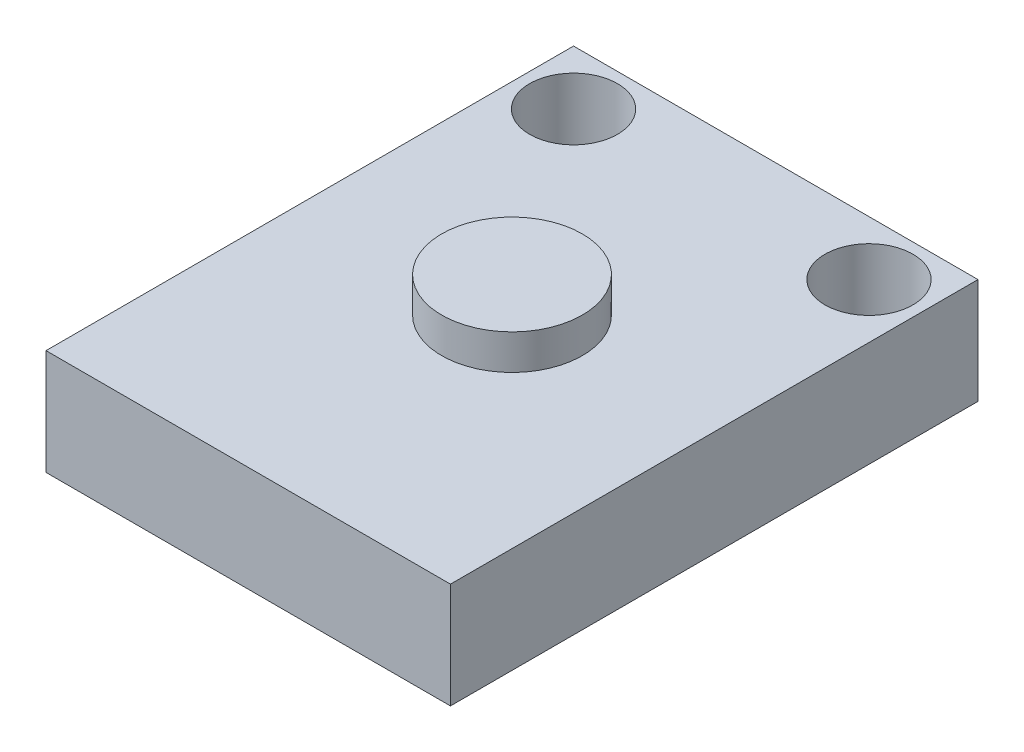
from build123d import *

# Parameters (mm, degrees)
SKETCH1_W           = 23
SKETCH1_H           = 30
SKETCH1_R           = 2.5
BOSS_EXTRUDE1_DEPTH = 6
BOSS_EXTRUDE2_START = -6
SKETCH2_R           = 4
BOSS_EXTRUDE2_DEPTH = 8


with BuildPart() as part:
    # Sketch1 → Boss-Extrude1 (new body)
    with BuildSketch(Plane(origin=(0, 0, 0), x_dir=(1, 0, 0), z_dir=(0, 1, 0))):
        Rectangle(SKETCH1_W, SKETCH1_H)
        with Locations((-8.4, 11.9)):
            Circle(SKETCH1_R, mode=Mode.SUBTRACT)
        with Locations((8.4, 11.9)):
            Circle(SKETCH1_R, mode=Mode.SUBTRACT)
    extrude(amount=BOSS_EXTRUDE1_DEPTH)

    # Sketch2 → Boss-Extrude2 (add)
    with BuildSketch(Plane(origin=(0, 6, 0), x_dir=(1, 0, 0), z_dir=(0, 1, 0)).offset(BOSS_EXTRUDE2_START)):
        Circle(SKETCH2_R)
    extrude(amount=BOSS_EXTRUDE2_DEPTH)


solid = part.part
